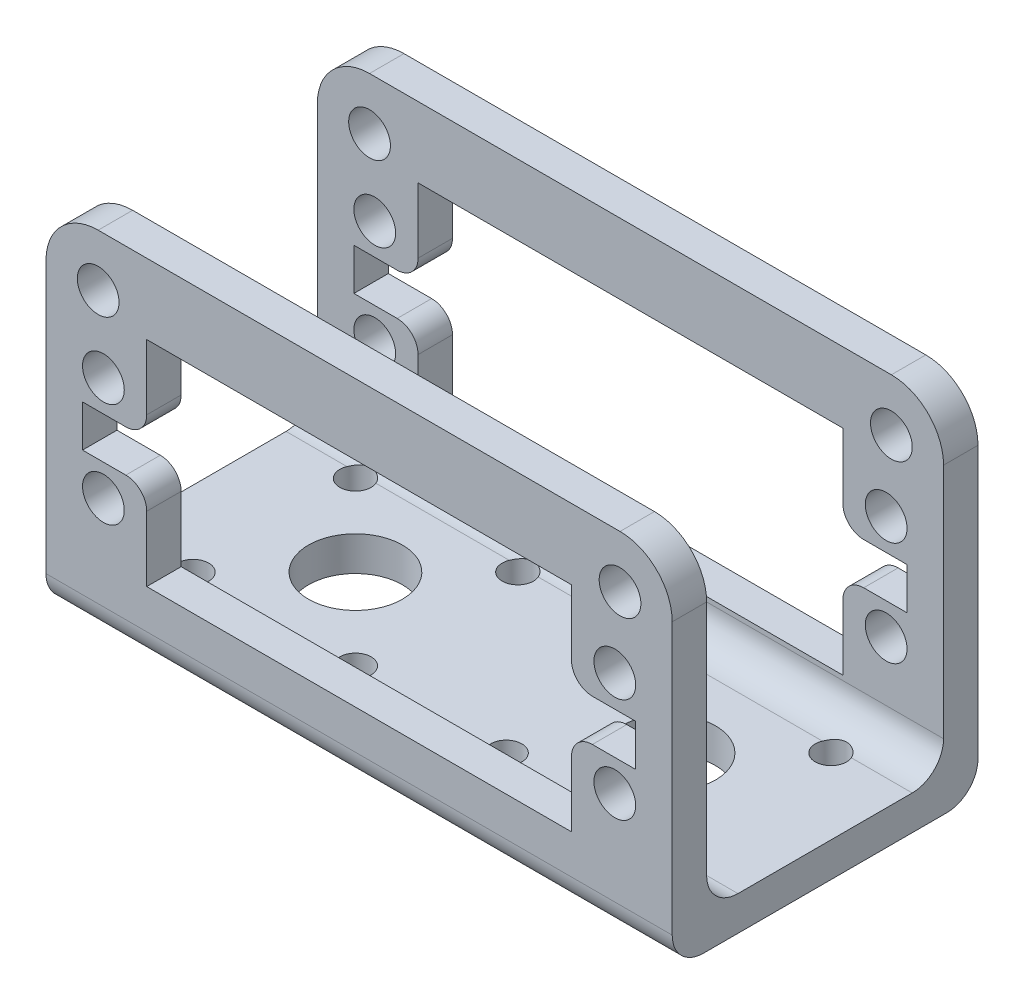
from build123d import *

# Parameters (mm, degrees)
SKETCH1_R           = 2
BOSS_EXTRUDE1_DEPTH = 3.3
SKETCH2_W           = 60
SKETCH2_H           = 3.3
BOSS_EXTRUDE2_DEPTH = 26
FILLET1_R           = 3
SKETCH4_R           = 1.5
SKETCH4_R_2         = 4.5
CUT_EXTRUDE1_DEPTH  = 18


with BuildPart() as part:
    # Sketch1 → Boss-Extrude1 (new body)
    with BuildSketch(Plane.XY):
        with BuildLine():
            Line((30, -17), (-30, -17))
            Line((-30, -17), (-30, 12))
            ThreePointArc((-30, 12), (-28.535533906, 15.535533906), (-25, 17))
            Line((-25, 17), (25, 17))
            ThreePointArc((25, 17), (28.535533906, 15.535533906), (30, 12))
            Line((30, 12), (30, -17))
        make_face()
        with Locations((-24.5, 5)):
            Circle(SKETCH1_R, mode=Mode.SUBTRACT)
        with Locations((24.5, 5)):
            Circle(SKETCH1_R, mode=Mode.SUBTRACT)
        with Locations((24.5, -5)):
            Circle(SKETCH1_R, mode=Mode.SUBTRACT)
        with Locations((-24.5, -5)):
            Circle(SKETCH1_R, mode=Mode.SUBTRACT)
        with Locations((-25, 12)):
            Circle(SKETCH1_R, mode=Mode.SUBTRACT)
        with Locations((25, 12)):
            Circle(SKETCH1_R, mode=Mode.SUBTRACT)
        with BuildLine():
            Line((-20.35, -4), (-20.35, -10.25))
            Line((-20.35, -10.25), (20.35, -10.25))
            Line((20.35, -10.25), (20.35, -4))
            ThreePointArc((20.35, -4), (20.935786438, -2.585786438), (22.35, -2))
            Line((22.35, -2), (26.5, -2))
            Line((26.5, -2), (26.5, 2))
            Line((26.5, 2), (22.35, 2))
            ThreePointArc((22.35, 2), (20.935786438, 2.585786438), (20.35, 4))
            Line((20.35, 4), (20.35, 10.25))
            Line((20.35, 10.25), (-20.35, 10.25))
            Line((-20.35, 10.25), (-20.35, 4))
            ThreePointArc((-20.35, 4), (-20.935786438, 2.585786438), (-22.35, 2))
            Line((-22.35, 2), (-26.5, 2))
            Line((-26.5, 2), (-26.5, -2))
            Line((-26.5, -2), (-22.35, -2))
            ThreePointArc((-22.35, -2), (-20.935786438, -2.585786438), (-20.35, -4))
        make_face(mode=Mode.SUBTRACT)
    boss_extrude1 = extrude(amount=BOSS_EXTRUDE1_DEPTH)

    # Sketch2 → Boss-Extrude2 (add)
    with BuildSketch(Plane.XY.offset(3.3)):
        with Locations((0, -15.35)):
            Rectangle(SKETCH2_W, SKETCH2_H)
    extrude(amount=-BOSS_EXTRUDE2_DEPTH)

    # Mirror1: Boss-Extrude1 across plane
    add(boss_extrude1.mirror(Plane.XY.offset(-11.35)))

    # Fillet1
    fillet1_edges = [part.edges().sort_by_distance(p)[0] for p in [
        (0, -13.7, -22.7),
        (0, -13.7, 0),
        (0, -17, -26),
        (0, -17, 3.3),
    ]]
    fillet(fillet1_edges, radius=FILLET1_R)

    # Sketch4 → Cut-Extrude1 (cut)
    with BuildSketch(Plane.XZ.offset(17)):
        with Locations((-22.778174593, -3.571825407)):
            Circle(SKETCH4_R)
        with Locations((-7.221825407, -3.571825407)):
            Circle(SKETCH4_R)
        with Locations((-7.221825407, -19.128174593)):
            Circle(SKETCH4_R)
        with Locations((-22.778174593, -19.128174593)):
            Circle(SKETCH4_R)
        with Locations((22.778174593, -19.128174593)):
            Circle(SKETCH4_R)
        with Locations((7.221825407, -19.128174593)):
            Circle(SKETCH4_R)
        with Locations((7.221825407, -3.571825407)):
            Circle(SKETCH4_R)
        with Locations((22.778174593, -3.571825407)):
            Circle(SKETCH4_R)
        with Locations((-15, -11.35)):
            Circle(SKETCH4_R_2)
        with Locations((15, -11.35)):
            Circle(SKETCH4_R_2)
    extrude(amount=-CUT_EXTRUDE1_DEPTH, mode=Mode.SUBTRACT)


solid = part.part
